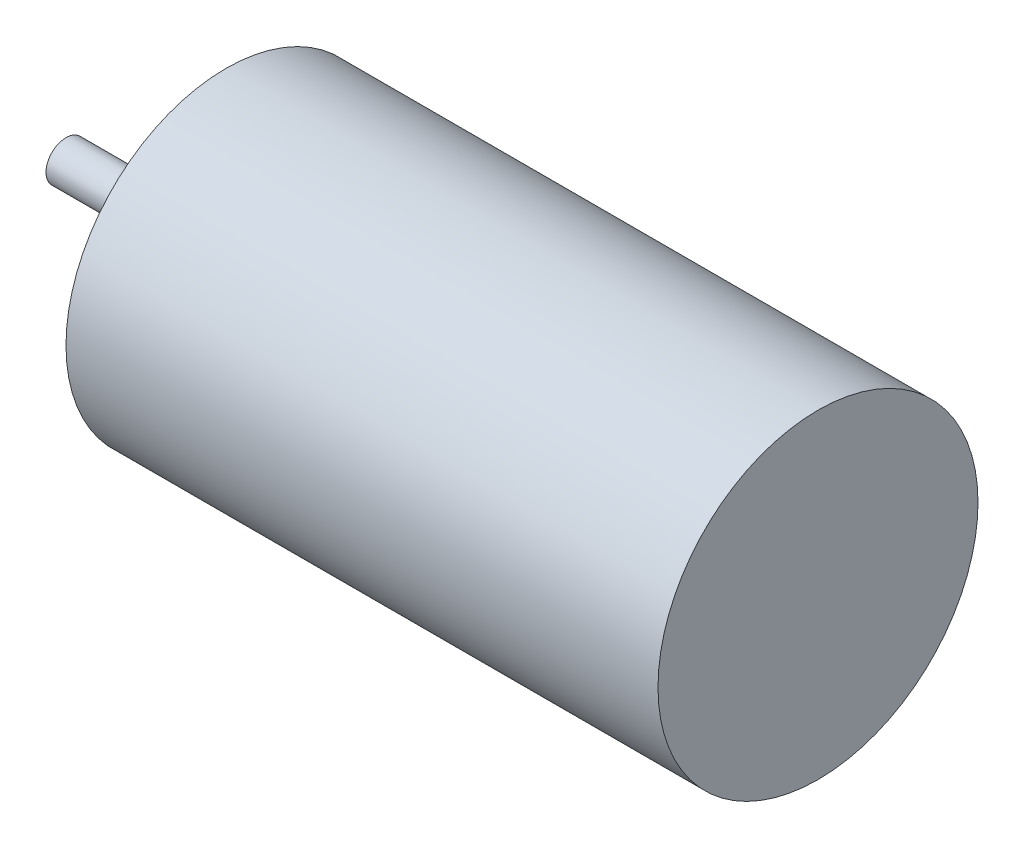
from build123d import *

# Parameters (mm, degrees)
SKETCH1_R           = 20
BOSS_EXTRUDE1_DEPTH = 74
SKETCH2_R           = 2.5
BOSS_EXTRUDE2_DEPTH = 20


with BuildPart() as part:
    # Sketch1 → Boss-Extrude1 (new body)
    with BuildSketch(Plane(origin=(0, 0, 0), x_dir=(0, 0, -1), z_dir=(1, 0, 0))):
        Circle(SKETCH1_R)
    extrude(amount=BOSS_EXTRUDE1_DEPTH)

    # Sketch2 → Boss-Extrude2 (add)
    with BuildSketch(Plane.ZY):
        Circle(SKETCH2_R)
    extrude(amount=BOSS_EXTRUDE2_DEPTH)


solid = part.part
